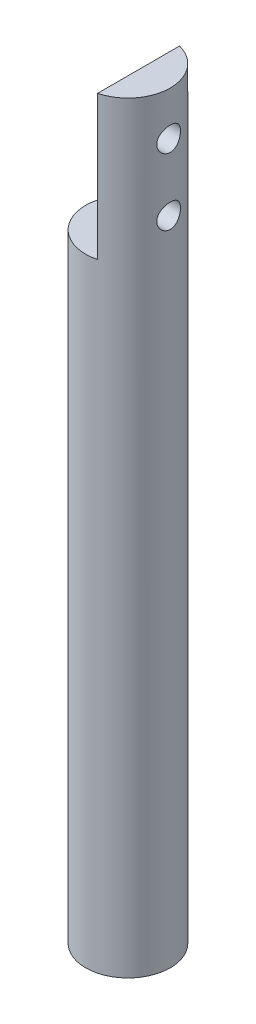
from build123d import *

# Parameters (mm, degrees)
SKETCH_1_R          = 3.175
EXTRUDE_1_DEPTH     = 57.15
CUT_EXTRUDE_1_DEPTH = 10.795
SKETCH_3_R          = 0.889
CUT_EXTRUDE_2_DEPTH = 10.795
SKETCH_4_W          = 3.926157487
SKETCH_4_H          = 0.79375
CUT_EXTRUDE_3_DEPTH = 8.573


with BuildPart() as part:
    # 草图1 → 凸台-拉伸1 (new body)
    with BuildSketch(Plane(origin=(0, 0, 0), x_dir=(1, 0, 0), z_dir=(0, 1, 0))):
        Circle(SKETCH_1_R)
    extrude(amount=EXTRUDE_1_DEPTH)

    # 草图2 → 切除-拉伸1 (cut)
    with BuildSketch(Plane(origin=(0, 57.15, 0), x_dir=(1, 0, 0), z_dir=(0, 1, 0))):
        Polygon((-0.794, 3.175), (0.794, 3.175), (0.794, -3.175), (-3.175, -3.175), (-3.175, 3.175), align=None)
    extrude(amount=-CUT_EXTRUDE_1_DEPTH, mode=Mode.SUBTRACT)

    # 草图3 → 切除-拉伸2 (cut)
    with BuildSketch(Plane.ZY.offset(-0.794)):
        with Locations((0, 53.855)):
            Circle(SKETCH_3_R)
        with Locations((0, 48.855)):
            Circle(SKETCH_3_R)
    extrude(amount=-CUT_EXTRUDE_2_DEPTH, mode=Mode.SUBTRACT)

    # 草图4 → 切除-拉伸3 (cut)
    with BuildSketch(Plane.XZ):
        with Locations((-0.018009896, -2.778125)):
            Rectangle(SKETCH_4_W, SKETCH_4_H)
    extrude(amount=-CUT_EXTRUDE_3_DEPTH, mode=Mode.SUBTRACT)


solid = part.part
